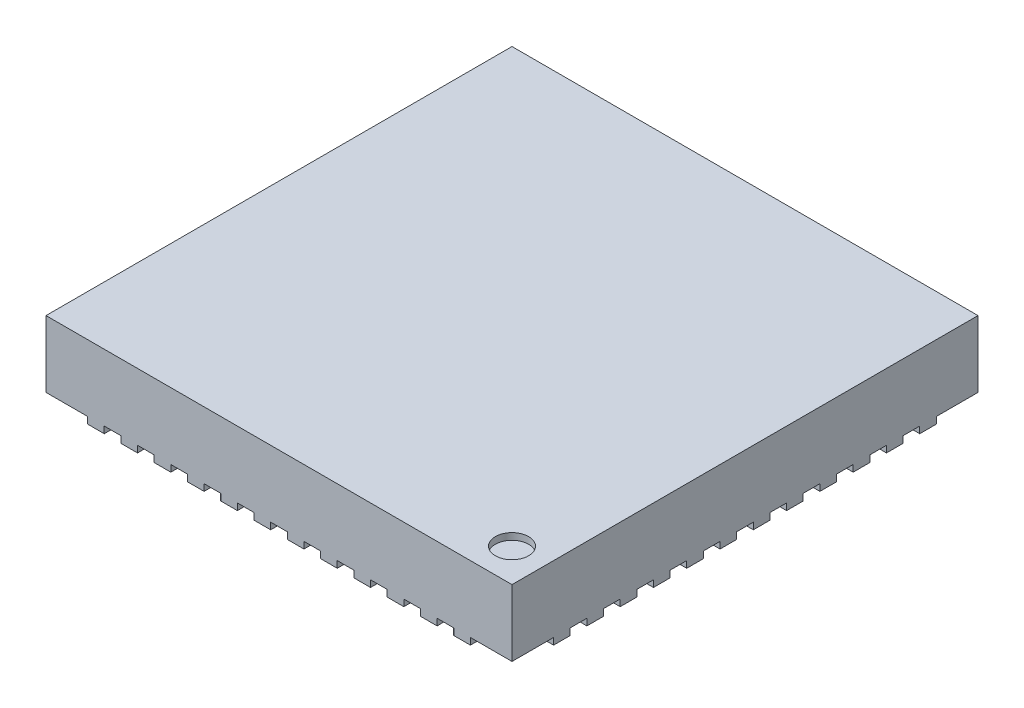
from build123d import *

# Parameters (mm, degrees)
SKETCH1_W            = 7
SKETCH1_H            = 7
BOSS_EXTRUDE1_DEPTH  = 1
BOSS_EXTRUDE2_DEPTH  = 0.1
BOSS_EXTRUDE3_DEPTH  = 0.1
BOSS_EXTRUDE4_DEPTH  = 0.1
BOSS_EXTRUDE5_DEPTH  = 0.1
BOSS_EXTRUDE6_DEPTH  = 0.1
BOSS_EXTRUDE7_DEPTH  = 0.1
BOSS_EXTRUDE8_DEPTH  = 0.1
BOSS_EXTRUDE9_DEPTH  = 0.1
BOSS_EXTRUDE10_DEPTH = 0.1
BOSS_EXTRUDE11_DEPTH = 0.1
BOSS_EXTRUDE12_DEPTH = 0.1
BOSS_EXTRUDE13_DEPTH = 0.1
BOSS_EXTRUDE14_DEPTH = 0.1
BOSS_EXTRUDE15_DEPTH = 0.1
BOSS_EXTRUDE16_DEPTH = 0.1
BOSS_EXTRUDE17_DEPTH = 0.1
BOSS_EXTRUDE18_DEPTH = 0.1
BOSS_EXTRUDE19_DEPTH = 0.1
BOSS_EXTRUDE20_DEPTH = 0.1
BOSS_EXTRUDE21_DEPTH = 0.1
BOSS_EXTRUDE22_DEPTH = 0.1
BOSS_EXTRUDE23_DEPTH = 0.1
BOSS_EXTRUDE24_DEPTH = 0.1
BOSS_EXTRUDE25_DEPTH = 0.1
BOSS_EXTRUDE26_DEPTH = 0.1
BOSS_EXTRUDE27_DEPTH = 0.1
BOSS_EXTRUDE28_DEPTH = 0.1
BOSS_EXTRUDE29_DEPTH = 0.1
BOSS_EXTRUDE30_DEPTH = 0.1
BOSS_EXTRUDE31_DEPTH = 0.1
BOSS_EXTRUDE32_DEPTH = 0.1
BOSS_EXTRUDE33_DEPTH = 0.1
BOSS_EXTRUDE34_DEPTH = 0.1
BOSS_EXTRUDE35_DEPTH = 0.1
BOSS_EXTRUDE36_DEPTH = 0.1
BOSS_EXTRUDE37_DEPTH = 0.1
BOSS_EXTRUDE38_DEPTH = 0.1
BOSS_EXTRUDE39_DEPTH = 0.1
BOSS_EXTRUDE40_DEPTH = 0.1
BOSS_EXTRUDE41_DEPTH = 0.1
BOSS_EXTRUDE42_DEPTH = 0.1
BOSS_EXTRUDE43_DEPTH = 0.1
BOSS_EXTRUDE44_DEPTH = 0.1
BOSS_EXTRUDE45_DEPTH = 0.1
BOSS_EXTRUDE46_DEPTH = 0.1
BOSS_EXTRUDE47_DEPTH = 0.1
BOSS_EXTRUDE48_DEPTH = 0.1
BOSS_EXTRUDE49_DEPTH = 0.1
BOSS_EXTRUDE50_DEPTH = 0.1
SKETCH51_W           = 0.25
SKETCH51_H           = 0.1


with BuildPart() as part:
    # Sketch1 → Boss-Extrude1 (new body)
    with BuildSketch(Plane.XZ):
        Rectangle(SKETCH1_W, SKETCH1_H)
    extrude(amount=-BOSS_EXTRUDE1_DEPTH)

    # Sketch2 → Boss-Extrude2 (add)
    with BuildSketch(Plane.XZ):
        with BuildLine():
            Line((-3.5, 2.875), (-3.225, 2.875))
            ThreePointArc((-3.225, 2.875), (-3.1, 2.75), (-3.225, 2.625))
            Line((-3.225, 2.625), (-3.5, 2.625))
            Line((-3.5, 2.625), (-3.5, 2.875))
        make_face()
    extrude(amount=BOSS_EXTRUDE2_DEPTH)

    # Sketch3 → Boss-Extrude3 (add)
    with BuildSketch(Plane.XZ):
        with BuildLine():
            Line((-3.5, 2.375), (-3.225, 2.375))
            ThreePointArc((-3.225, 2.375), (-3.1, 2.25), (-3.225, 2.125))
            Line((-3.225, 2.125), (-3.5, 2.125))
            Line((-3.5, 2.125), (-3.5, 2.375))
        make_face()
    extrude(amount=BOSS_EXTRUDE3_DEPTH)

    # Sketch4 → Boss-Extrude4 (add)
    with BuildSketch(Plane.XZ):
        with BuildLine():
            Line((-3.5, 1.875), (-3.225, 1.875))
            ThreePointArc((-3.225, 1.875), (-3.1, 1.75), (-3.225, 1.625))
            Line((-3.225, 1.625), (-3.5, 1.625))
            Line((-3.5, 1.625), (-3.5, 1.875))
        make_face()
    extrude(amount=BOSS_EXTRUDE4_DEPTH)

    # Sketch5 → Boss-Extrude5 (add)
    with BuildSketch(Plane.XZ):
        with BuildLine():
            Line((-3.5, 1.375), (-3.225, 1.375))
            ThreePointArc((-3.225, 1.375), (-3.1, 1.25), (-3.225, 1.125))
            Line((-3.225, 1.125), (-3.5, 1.125))
            Line((-3.5, 1.125), (-3.5, 1.375))
        make_face()
    extrude(amount=BOSS_EXTRUDE5_DEPTH)

    # Sketch6 → Boss-Extrude6 (add)
    with BuildSketch(Plane.XZ):
        with BuildLine():
            Line((-3.5, 0.875), (-3.225, 0.875))
            ThreePointArc((-3.225, 0.875), (-3.1, 0.75), (-3.225, 0.625))
            Line((-3.225, 0.625), (-3.5, 0.625))
            Line((-3.5, 0.625), (-3.5, 0.875))
        make_face()
    extrude(amount=BOSS_EXTRUDE6_DEPTH)

    # Sketch7 → Boss-Extrude7 (add)
    with BuildSketch(Plane.XZ):
        with BuildLine():
            Line((-3.5, 0.375), (-3.225, 0.375))
            ThreePointArc((-3.225, 0.375), (-3.1, 0.25), (-3.225, 0.125))
            Line((-3.225, 0.125), (-3.5, 0.125))
            Line((-3.5, 0.125), (-3.5, 0.375))
        make_face()
    extrude(amount=BOSS_EXTRUDE7_DEPTH)

    # Sketch8 → Boss-Extrude8 (add)
    with BuildSketch(Plane.XZ):
        with BuildLine():
            Line((-3.5, -0.125), (-3.225, -0.125))
            ThreePointArc((-3.225, -0.125), (-3.1, -0.25), (-3.225, -0.375))
            Line((-3.225, -0.375), (-3.5, -0.375))
            Line((-3.5, -0.375), (-3.5, -0.125))
        make_face()
    extrude(amount=BOSS_EXTRUDE8_DEPTH)

    # Sketch9 → Boss-Extrude9 (add)
    with BuildSketch(Plane.XZ):
        with BuildLine():
            Line((-3.5, -0.625), (-3.225, -0.625))
            ThreePointArc((-3.225, -0.625), (-3.1, -0.75), (-3.225, -0.875))
            Line((-3.225, -0.875), (-3.5, -0.875))
            Line((-3.5, -0.875), (-3.5, -0.625))
        make_face()
    extrude(amount=BOSS_EXTRUDE9_DEPTH)

    # Sketch10 → Boss-Extrude10 (add)
    with BuildSketch(Plane.XZ):
        with BuildLine():
            Line((-3.5, -1.125), (-3.225, -1.125))
            ThreePointArc((-3.225, -1.125), (-3.1, -1.25), (-3.225, -1.375))
            Line((-3.225, -1.375), (-3.5, -1.375))
            Line((-3.5, -1.375), (-3.5, -1.125))
        make_face()
    extrude(amount=BOSS_EXTRUDE10_DEPTH)

    # Sketch11 → Boss-Extrude11 (add)
    with BuildSketch(Plane.XZ):
        with BuildLine():
            Line((-3.5, -1.625), (-3.225, -1.625))
            ThreePointArc((-3.225, -1.625), (-3.1, -1.75), (-3.225, -1.875))
            Line((-3.225, -1.875), (-3.5, -1.875))
            Line((-3.5, -1.875), (-3.5, -1.625))
        make_face()
    extrude(amount=BOSS_EXTRUDE11_DEPTH)

    # Sketch12 → Boss-Extrude12 (add)
    with BuildSketch(Plane.XZ):
        with BuildLine():
            Line((-3.5, -2.125), (-3.225, -2.125))
            ThreePointArc((-3.225, -2.125), (-3.1, -2.25), (-3.225, -2.375))
            Line((-3.225, -2.375), (-3.5, -2.375))
            Line((-3.5, -2.375), (-3.5, -2.125))
        make_face()
    extrude(amount=BOSS_EXTRUDE12_DEPTH)

    # Sketch13 → Boss-Extrude13 (add)
    with BuildSketch(Plane.XZ):
        with BuildLine():
            Line((-3.5, -2.625), (-3.225, -2.625))
            ThreePointArc((-3.225, -2.625), (-3.1, -2.75), (-3.225, -2.875))
            Line((-3.225, -2.875), (-3.5, -2.875))
            Line((-3.5, -2.875), (-3.5, -2.625))
        make_face()
    extrude(amount=BOSS_EXTRUDE13_DEPTH)

    # Sketch14 → Boss-Extrude14 (add)
    with BuildSketch(Plane.XZ):
        with BuildLine():
            Line((-2.875, -3.5), (-2.875, -3.225))
            ThreePointArc((-2.875, -3.225), (-2.75, -3.1), (-2.625, -3.225))
            Line((-2.625, -3.225), (-2.625, -3.5))
            Line((-2.625, -3.5), (-2.875, -3.5))
        make_face()
    extrude(amount=BOSS_EXTRUDE14_DEPTH)

    # Sketch15 → Boss-Extrude15 (add)
    with BuildSketch(Plane.XZ):
        with BuildLine():
            Line((-2.375, -3.5), (-2.375, -3.225))
            ThreePointArc((-2.375, -3.225), (-2.25, -3.1), (-2.125, -3.225))
            Line((-2.125, -3.225), (-2.125, -3.5))
            Line((-2.125, -3.5), (-2.375, -3.5))
        make_face()
    extrude(amount=BOSS_EXTRUDE15_DEPTH)

    # Sketch16 → Boss-Extrude16 (add)
    with BuildSketch(Plane.XZ):
        with BuildLine():
            Line((-1.875, -3.5), (-1.875, -3.225))
            ThreePointArc((-1.875, -3.225), (-1.75, -3.1), (-1.625, -3.225))
            Line((-1.625, -3.225), (-1.625, -3.5))
            Line((-1.625, -3.5), (-1.875, -3.5))
        make_face()
    extrude(amount=BOSS_EXTRUDE16_DEPTH)

    # Sketch17 → Boss-Extrude17 (add)
    with BuildSketch(Plane.XZ):
        with BuildLine():
            Line((-1.375, -3.5), (-1.375, -3.225))
            ThreePointArc((-1.375, -3.225), (-1.25, -3.1), (-1.125, -3.225))
            Line((-1.125, -3.225), (-1.125, -3.5))
            Line((-1.125, -3.5), (-1.375, -3.5))
        make_face()
    extrude(amount=BOSS_EXTRUDE17_DEPTH)

    # Sketch18 → Boss-Extrude18 (add)
    with BuildSketch(Plane.XZ):
        with BuildLine():
            Line((-0.875, -3.5), (-0.875, -3.225))
            ThreePointArc((-0.875, -3.225), (-0.75, -3.1), (-0.625, -3.225))
            Line((-0.625, -3.225), (-0.625, -3.5))
            Line((-0.625, -3.5), (-0.875, -3.5))
        make_face()
    extrude(amount=BOSS_EXTRUDE18_DEPTH)

    # Sketch19 → Boss-Extrude19 (add)
    with BuildSketch(Plane.XZ):
        with BuildLine():
            Line((-0.375, -3.5), (-0.375, -3.225))
            ThreePointArc((-0.375, -3.225), (-0.25, -3.1), (-0.125, -3.225))
            Line((-0.125, -3.225), (-0.125, -3.5))
            Line((-0.125, -3.5), (-0.375, -3.5))
        make_face()
    extrude(amount=BOSS_EXTRUDE19_DEPTH)

    # Sketch20 → Boss-Extrude20 (add)
    with BuildSketch(Plane.XZ):
        with BuildLine():
            Line((0.125, -3.5), (0.125, -3.225))
            ThreePointArc((0.125, -3.225), (0.25, -3.1), (0.375, -3.225))
            Line((0.375, -3.225), (0.375, -3.5))
            Line((0.375, -3.5), (0.125, -3.5))
        make_face()
    extrude(amount=BOSS_EXTRUDE20_DEPTH)

    # Sketch21 → Boss-Extrude21 (add)
    with BuildSketch(Plane.XZ):
        with BuildLine():
            Line((0.625, -3.5), (0.625, -3.225))
            ThreePointArc((0.625, -3.225), (0.75, -3.1), (0.875, -3.225))
            Line((0.875, -3.225), (0.875, -3.5))
            Line((0.875, -3.5), (0.625, -3.5))
        make_face()
    extrude(amount=BOSS_EXTRUDE21_DEPTH)

    # Sketch22 → Boss-Extrude22 (add)
    with BuildSketch(Plane.XZ):
        with BuildLine():
            Line((1.125, -3.5), (1.125, -3.225))
            ThreePointArc((1.125, -3.225), (1.25, -3.1), (1.375, -3.225))
            Line((1.375, -3.225), (1.375, -3.5))
            Line((1.375, -3.5), (1.125, -3.5))
        make_face()
    extrude(amount=BOSS_EXTRUDE22_DEPTH)

    # Sketch23 → Boss-Extrude23 (add)
    with BuildSketch(Plane.XZ):
        with BuildLine():
            Line((1.625, -3.5), (1.625, -3.225))
            ThreePointArc((1.625, -3.225), (1.75, -3.1), (1.875, -3.225))
            Line((1.875, -3.225), (1.875, -3.5))
            Line((1.875, -3.5), (1.625, -3.5))
        make_face()
    extrude(amount=BOSS_EXTRUDE23_DEPTH)

    # Sketch24 → Boss-Extrude24 (add)
    with BuildSketch(Plane.XZ):
        with BuildLine():
            Line((2.125, -3.5), (2.125, -3.225))
            ThreePointArc((2.125, -3.225), (2.25, -3.1), (2.375, -3.225))
            Line((2.375, -3.225), (2.375, -3.5))
            Line((2.375, -3.5), (2.125, -3.5))
        make_face()
    extrude(amount=BOSS_EXTRUDE24_DEPTH)

    # Sketch25 → Boss-Extrude25 (add)
    with BuildSketch(Plane.XZ):
        with BuildLine():
            Line((2.625, -3.5), (2.625, -3.225))
            ThreePointArc((2.625, -3.225), (2.75, -3.1), (2.875, -3.225))
            Line((2.875, -3.225), (2.875, -3.5))
            Line((2.875, -3.5), (2.625, -3.5))
        make_face()
    extrude(amount=BOSS_EXTRUDE25_DEPTH)

    # Sketch26 → Boss-Extrude26 (add)
    with BuildSketch(Plane.XZ):
        with BuildLine():
            Line((3.5, -2.875), (3.225, -2.875))
            ThreePointArc((3.225, -2.875), (3.1, -2.75), (3.225, -2.625))
            Line((3.225, -2.625), (3.5, -2.625))
            Line((3.5, -2.625), (3.5, -2.875))
        make_face()
    extrude(amount=BOSS_EXTRUDE26_DEPTH)

    # Sketch27 → Boss-Extrude27 (add)
    with BuildSketch(Plane.XZ):
        with BuildLine():
            Line((3.5, -2.375), (3.225, -2.375))
            ThreePointArc((3.225, -2.375), (3.1, -2.25), (3.225, -2.125))
            Line((3.225, -2.125), (3.5, -2.125))
            Line((3.5, -2.125), (3.5, -2.375))
        make_face()
    extrude(amount=BOSS_EXTRUDE27_DEPTH)

    # Sketch28 → Boss-Extrude28 (add)
    with BuildSketch(Plane.XZ):
        with BuildLine():
            Line((3.5, -1.875), (3.225, -1.875))
            ThreePointArc((3.225, -1.875), (3.1, -1.75), (3.225, -1.625))
            Line((3.225, -1.625), (3.5, -1.625))
            Line((3.5, -1.625), (3.5, -1.875))
        make_face()
    extrude(amount=BOSS_EXTRUDE28_DEPTH)

    # Sketch29 → Boss-Extrude29 (add)
    with BuildSketch(Plane.XZ):
        with BuildLine():
            Line((3.5, -1.375), (3.225, -1.375))
            ThreePointArc((3.225, -1.375), (3.1, -1.25), (3.225, -1.125))
            Line((3.225, -1.125), (3.5, -1.125))
            Line((3.5, -1.125), (3.5, -1.375))
        make_face()
    extrude(amount=BOSS_EXTRUDE29_DEPTH)

    # Sketch30 → Boss-Extrude30 (add)
    with BuildSketch(Plane.XZ):
        with BuildLine():
            Line((3.5, -0.875), (3.225, -0.875))
            ThreePointArc((3.225, -0.875), (3.1, -0.75), (3.225, -0.625))
            Line((3.225, -0.625), (3.5, -0.625))
            Line((3.5, -0.625), (3.5, -0.875))
        make_face()
    extrude(amount=BOSS_EXTRUDE30_DEPTH)

    # Sketch31 → Boss-Extrude31 (add)
    with BuildSketch(Plane.XZ):
        with BuildLine():
            Line((3.5, -0.375), (3.225, -0.375))
            ThreePointArc((3.225, -0.375), (3.1, -0.25), (3.225, -0.125))
            Line((3.225, -0.125), (3.5, -0.125))
            Line((3.5, -0.125), (3.5, -0.375))
        make_face()
    extrude(amount=BOSS_EXTRUDE31_DEPTH)

    # Sketch32 → Boss-Extrude32 (add)
    with BuildSketch(Plane.XZ):
        with BuildLine():
            Line((3.5, 0.125), (3.225, 0.125))
            ThreePointArc((3.225, 0.125), (3.1, 0.25), (3.225, 0.375))
            Line((3.225, 0.375), (3.5, 0.375))
            Line((3.5, 0.375), (3.5, 0.125))
        make_face()
    extrude(amount=BOSS_EXTRUDE32_DEPTH)

    # Sketch33 → Boss-Extrude33 (add)
    with BuildSketch(Plane.XZ):
        with BuildLine():
            Line((3.5, 0.625), (3.225, 0.625))
            ThreePointArc((3.225, 0.625), (3.1, 0.75), (3.225, 0.875))
            Line((3.225, 0.875), (3.5, 0.875))
            Line((3.5, 0.875), (3.5, 0.625))
        make_face()
    extrude(amount=BOSS_EXTRUDE33_DEPTH)

    # Sketch34 → Boss-Extrude34 (add)
    with BuildSketch(Plane.XZ):
        with BuildLine():
            Line((3.5, 1.125), (3.225, 1.125))
            ThreePointArc((3.225, 1.125), (3.1, 1.25), (3.225, 1.375))
            Line((3.225, 1.375), (3.5, 1.375))
            Line((3.5, 1.375), (3.5, 1.125))
        make_face()
    extrude(amount=BOSS_EXTRUDE34_DEPTH)

    # Sketch35 → Boss-Extrude35 (add)
    with BuildSketch(Plane.XZ):
        with BuildLine():
            Line((3.5, 1.625), (3.225, 1.625))
            ThreePointArc((3.225, 1.625), (3.1, 1.75), (3.225, 1.875))
            Line((3.225, 1.875), (3.5, 1.875))
            Line((3.5, 1.875), (3.5, 1.625))
        make_face()
    extrude(amount=BOSS_EXTRUDE35_DEPTH)

    # Sketch36 → Boss-Extrude36 (add)
    with BuildSketch(Plane.XZ):
        with BuildLine():
            Line((3.5, 2.125), (3.225, 2.125))
            ThreePointArc((3.225, 2.125), (3.1, 2.25), (3.225, 2.375))
            Line((3.225, 2.375), (3.5, 2.375))
            Line((3.5, 2.375), (3.5, 2.125))
        make_face()
    extrude(amount=BOSS_EXTRUDE36_DEPTH)

    # Sketch37 → Boss-Extrude37 (add)
    with BuildSketch(Plane.XZ):
        with BuildLine():
            Line((3.5, 2.625), (3.225, 2.625))
            ThreePointArc((3.225, 2.625), (3.1, 2.75), (3.225, 2.875))
            Line((3.225, 2.875), (3.5, 2.875))
            Line((3.5, 2.875), (3.5, 2.625))
        make_face()
    extrude(amount=BOSS_EXTRUDE37_DEPTH)

    # Sketch38 → Boss-Extrude38 (add)
    with BuildSketch(Plane.XZ):
        with BuildLine():
            Line((2.375, 3.5), (2.375, 3.225))
            ThreePointArc((2.375, 3.225), (2.25, 3.1), (2.125, 3.225))
            Line((2.125, 3.225), (2.125, 3.5))
            Line((2.125, 3.5), (2.375, 3.5))
        make_face()
    extrude(amount=BOSS_EXTRUDE38_DEPTH)

    # Sketch39 → Boss-Extrude39 (add)
    with BuildSketch(Plane.XZ):
        with BuildLine():
            Line((1.875, 3.5), (1.875, 3.225))
            ThreePointArc((1.875, 3.225), (1.75, 3.1), (1.625, 3.225))
            Line((1.625, 3.225), (1.625, 3.5))
            Line((1.625, 3.5), (1.875, 3.5))
        make_face()
    extrude(amount=BOSS_EXTRUDE39_DEPTH)

    # Sketch40 → Boss-Extrude40 (add)
    with BuildSketch(Plane.XZ):
        with BuildLine():
            Line((1.375, 3.5), (1.375, 3.225))
            ThreePointArc((1.375, 3.225), (1.25, 3.1), (1.125, 3.225))
            Line((1.125, 3.225), (1.125, 3.5))
            Line((1.125, 3.5), (1.375, 3.5))
        make_face()
    extrude(amount=BOSS_EXTRUDE40_DEPTH)

    # Sketch41 → Boss-Extrude41 (add)
    with BuildSketch(Plane.XZ):
        with BuildLine():
            Line((0.875, 3.5), (0.875, 3.225))
            ThreePointArc((0.875, 3.225), (0.75, 3.1), (0.625, 3.225))
            Line((0.625, 3.225), (0.625, 3.5))
            Line((0.625, 3.5), (0.875, 3.5))
        make_face()
    extrude(amount=BOSS_EXTRUDE41_DEPTH)

    # Sketch42 → Boss-Extrude42 (add)
    with BuildSketch(Plane.XZ):
        with BuildLine():
            Line((0.375, 3.5), (0.375, 3.225))
            ThreePointArc((0.375, 3.225), (0.25, 3.1), (0.125, 3.225))
            Line((0.125, 3.225), (0.125, 3.5))
            Line((0.125, 3.5), (0.375, 3.5))
        make_face()
    extrude(amount=BOSS_EXTRUDE42_DEPTH)

    # Sketch43 → Boss-Extrude43 (add)
    with BuildSketch(Plane.XZ):
        with BuildLine():
            Line((-0.125, 3.5), (-0.125, 3.225))
            ThreePointArc((-0.125, 3.225), (-0.25, 3.1), (-0.375, 3.225))
            Line((-0.375, 3.225), (-0.375, 3.5))
            Line((-0.375, 3.5), (-0.125, 3.5))
        make_face()
    extrude(amount=BOSS_EXTRUDE43_DEPTH)

    # Sketch44 → Boss-Extrude44 (add)
    with BuildSketch(Plane.XZ):
        with BuildLine():
            Line((-0.625, 3.5), (-0.625, 3.225))
            ThreePointArc((-0.625, 3.225), (-0.75, 3.1), (-0.875, 3.225))
            Line((-0.875, 3.225), (-0.875, 3.5))
            Line((-0.875, 3.5), (-0.625, 3.5))
        make_face()
    extrude(amount=BOSS_EXTRUDE44_DEPTH)

    # Sketch45 → Boss-Extrude45 (add)
    with BuildSketch(Plane.XZ):
        with BuildLine():
            Line((-1.125, 3.5), (-1.125, 3.225))
            ThreePointArc((-1.125, 3.225), (-1.25, 3.1), (-1.375, 3.225))
            Line((-1.375, 3.225), (-1.375, 3.5))
            Line((-1.375, 3.5), (-1.125, 3.5))
        make_face()
    extrude(amount=BOSS_EXTRUDE45_DEPTH)

    # Sketch46 → Boss-Extrude46 (add)
    with BuildSketch(Plane.XZ):
        with BuildLine():
            Line((-1.625, 3.5), (-1.625, 3.225))
            ThreePointArc((-1.625, 3.225), (-1.75, 3.1), (-1.875, 3.225))
            Line((-1.875, 3.225), (-1.875, 3.5))
            Line((-1.875, 3.5), (-1.625, 3.5))
        make_face()
    extrude(amount=BOSS_EXTRUDE46_DEPTH)

    # Sketch47 → Boss-Extrude47 (add)
    with BuildSketch(Plane.XZ):
        with BuildLine():
            Line((-2.125, 3.5), (-2.125, 3.225))
            ThreePointArc((-2.125, 3.225), (-2.25, 3.1), (-2.375, 3.225))
            Line((-2.375, 3.225), (-2.375, 3.5))
            Line((-2.375, 3.5), (-2.125, 3.5))
        make_face()
    extrude(amount=BOSS_EXTRUDE47_DEPTH)

    # Sketch48 → Boss-Extrude48 (add)
    with BuildSketch(Plane.XZ):
        with BuildLine():
            Line((-2.625, 3.5), (-2.625, 3.225))
            ThreePointArc((-2.625, 3.225), (-2.75, 3.1), (-2.875, 3.225))
            Line((-2.875, 3.225), (-2.875, 3.5))
            Line((-2.875, 3.5), (-2.625, 3.5))
        make_face()
    extrude(amount=BOSS_EXTRUDE48_DEPTH)

    # Sketch49 → Boss-Extrude49 (add)
    with BuildSketch(Plane.XZ):
        with BuildLine():
            Line((2.875, 3.5), (2.875, 3.225))
            ThreePointArc((2.875, 3.225), (2.75, 3.1), (2.625, 3.225))
            Line((2.625, 3.225), (2.625, 3.5))
            Line((2.625, 3.5), (2.875, 3.5))
        make_face()
    extrude(amount=BOSS_EXTRUDE49_DEPTH)

    # Sketch50 → Boss-Extrude50 (add)
    with BuildSketch(Plane.XZ):
        with BuildLine():
            Line((2.5, -2.75), (-2.5, -2.75))
            ThreePointArc((-2.5, -2.75), (-2.676776695, -2.676776695), (-2.75, -2.5))
            Line((-2.75, -2.5), (-2.75, 2.5))
            ThreePointArc((-2.75, 2.5), (-2.676776695, 2.676776695), (-2.5, 2.75))
            Line((-2.5, 2.75), (2.5, 2.75))
            Line((2.5, 2.75), (2.75, 2.5))
            Line((2.75, 2.5), (2.75, -2.5))
            ThreePointArc((2.75, -2.5), (2.676776695, -2.676776695), (2.5, -2.75))
        make_face()
    extrude(amount=BOSS_EXTRUDE50_DEPTH)

    # Sketch51 → Cut-Revolve1 (revolve, cut)
    with BuildSketch(Plane(origin=(0, 0, 3), x_dir=(-1, 0, 0), z_dir=(0, 0, -1))):
        with Locations((-3.125, 0.95)):
            Rectangle(SKETCH51_W, SKETCH51_H)
    revolve(axis=Axis((3, 0.9, 3), (0, 1, 0)), mode=Mode.SUBTRACT)


solid = part.part
